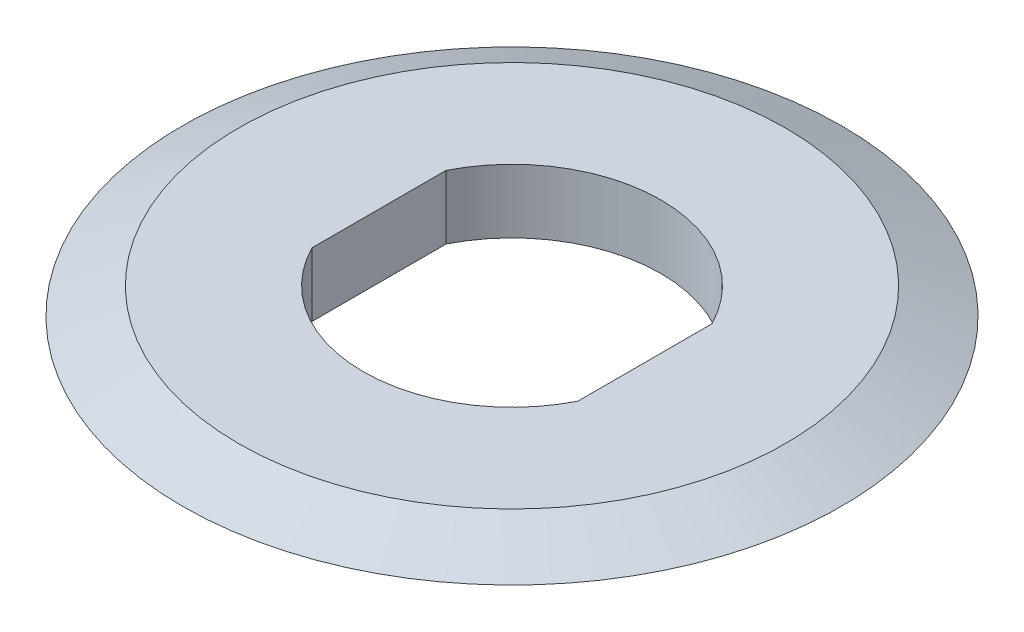
from build123d import *

# Parameters (mm, degrees)
SKETCH2_R           = 9.92
BOSS_EXTRUDE1_DEPTH = 0.96
CUT_EXTRUDE2_DEPTH  = 1.92
FILLET1_R           = 5


with BuildPart() as part:
    # Sketch2 → Boss-Extrude1 (new body, symmetric)
    with BuildSketch(Plane(origin=(0, 0, 0), x_dir=(1, 0, 0), z_dir=(0, 1, 0))):
        Circle(SKETCH2_R)
    extrude(amount=BOSS_EXTRUDE1_DEPTH, both=True)

    # Sketch3 → Cut-Revolve3 (revolve, cut)
    with BuildSketch(Plane.XY):
        Polygon((-9.92, 0.96), (-9.92, 0.171940058), (-8.23, 0.96), align=None)
        Polygon((-7.492546713, -0.96), (-9.92, 0.171940058), (-9.92, -0.96), align=None)
    revolve(axis=Axis((0, 0, 0), (0, 1, 0)), mode=Mode.SUBTRACT)

    # Sketch4 → Cut-Extrude2 (cut)
    with BuildSketch(Plane(origin=(0, 0.96, 0), x_dir=(1, 0, 0), z_dir=(0, 1, 0))):
        with BuildLine():
            Line((4, 0), (4, 2.017523234))
            ThreePointArc((4, 2.017523234), (0, 4.48), (-4, 2.017523234))
            Line((-4, 2.017523234), (-4, 0))
            Line((-4, 0), (-4, -2.017523234))
            ThreePointArc((-4, -2.017523234), (0, -4.48), (4, -2.017523234))
            Line((4, -2.017523234), (4, 0))
        make_face()
    extrude(amount=-CUT_EXTRUDE2_DEPTH, mode=Mode.SUBTRACT)

    # Fillet1
    fillet1_edges = [part.edges().sort_by_distance(p)[0] for p in [
        (7.492546713, -0.96, 0),
    ]]
    fillet(fillet1_edges, radius=FILLET1_R)


solid = part.part
